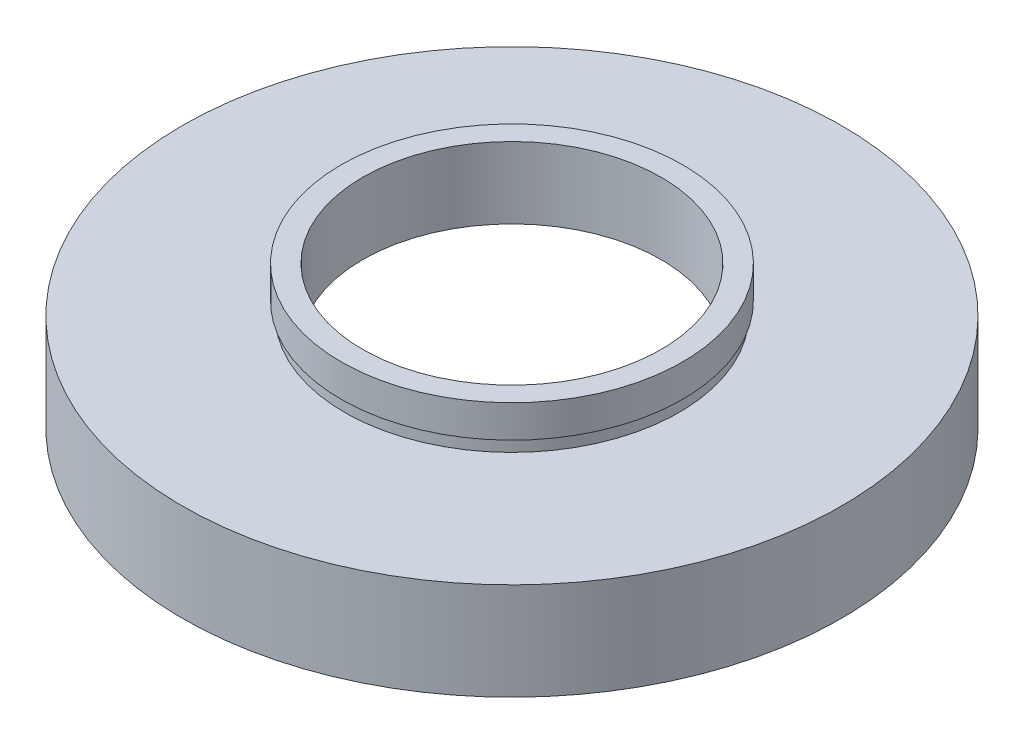
from build123d import *


with BuildPart() as part:
    # 草图1 → 旋转1 (revolve)
    with BuildSketch(Plane.XY, mode=Mode.PRIVATE) as revolve_1_sk:
        Polygon((23, 0), (23, 4.5), (24.1, 4.5), (24.1, 5.5), (11.5, 5.5), (11.5, 11), (13.16, 11), (13.16, 8.5), (12.9, 8.5), (12.9, 7.5), (25.4, 7.5), (25.4, 0), align=None)
    revolve(revolve_1_sk.sketch.rotate(Axis((0, 16.886018237, 0), (0, -1, 0)), 180), axis=Axis((0, 16.886018237, 0), (0, -1, 0)))  # turned: the seam where the file's is


solid = part.part
